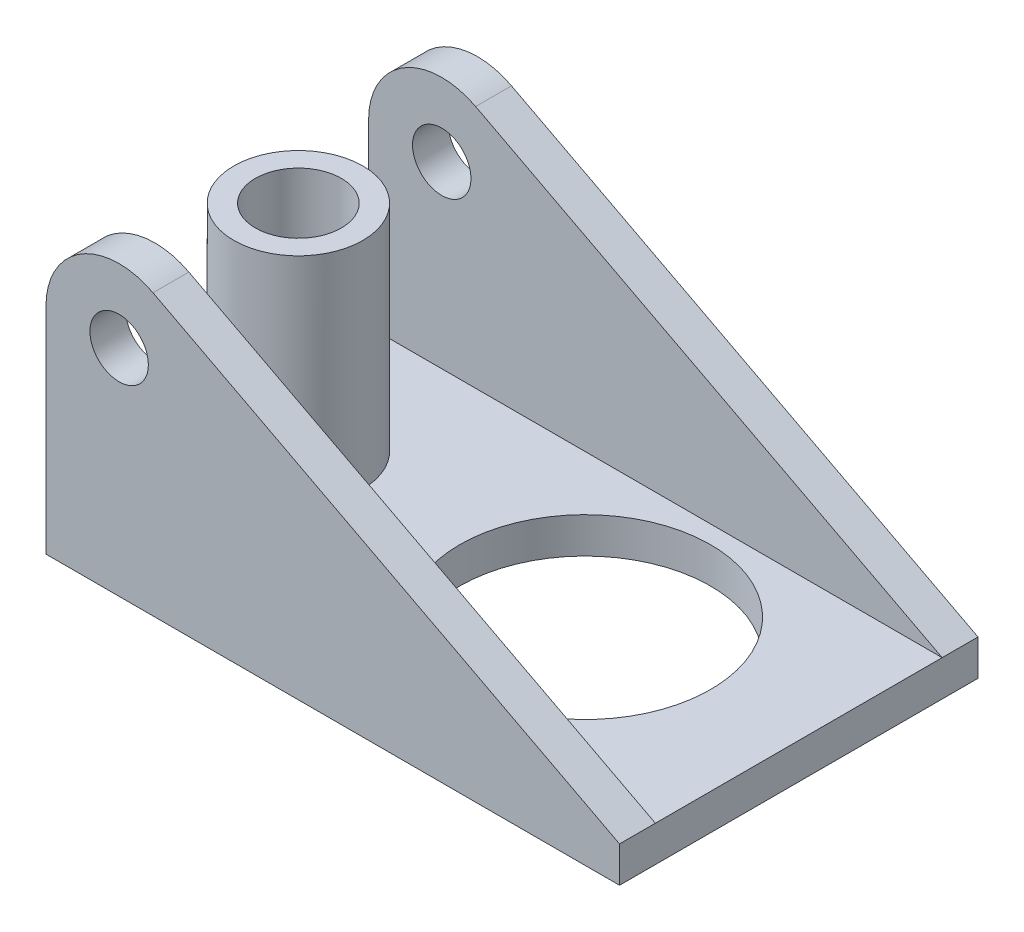
from build123d import *

# Parameters (mm, degrees)
SKETCH3_R           = 4.075
BOSS_EXTRUDE3_DEPTH = 50
CUT_EXTRUDE1_DEPTH  = 40
SKETCH8_R           = 6
SKETCH8_R_2         = 17.5
CUT_EXTRUDE2_DEPTH  = 6
SKETCH9_R           = 9
SKETCH9_R_2         = 6
BOSS_EXTRUDE4_DEPTH = 30


with BuildPart() as part:
    # Sketch3 → Boss-Extrude3 (new body)
    with BuildSketch(Plane.XY):
        with BuildLine():
            Line((0, 0), (0, 25))
            ThreePointArc((0, 25), (4.917135927, 33.725327913), (14.927715135, 34.038180658))
            Line((14.927715135, 34.038180658), (80, 0))
            Line((80, 0), (80, -5))
            Line((80, -5), (0, -5))
            Line((0, -5), (0, 0))
        make_face()
        with Locations((10.2, 25)):
            Circle(SKETCH3_R, mode=Mode.SUBTRACT)
    extrude(amount=BOSS_EXTRUDE3_DEPTH)

    # Sketch6 → Cut-Extrude1 (cut)
    with BuildSketch(Plane.XY.offset(45)):
        with BuildLine():
            Line((0, 25), (0, 0))
            Line((0, 0), (80, 0))
            Line((80, 0), (14.927715135, 34.038180658))
            ThreePointArc((14.927715135, 34.038180658), (4.917135927, 33.725327913), (0, 25))
        make_face()
    extrude(amount=-CUT_EXTRUDE1_DEPTH, mode=Mode.SUBTRACT)

    # Sketch8 → Cut-Extrude2 (cut, through all)
    with BuildSketch(Plane(origin=(0, 0, 0), x_dir=(1, 0, 0), z_dir=(0, 1, 0))):
        with Locations((10.2, -25)):
            Circle(SKETCH8_R)
        with Locations((50.2, -25)):
            Circle(SKETCH8_R_2)
    extrude(amount=-CUT_EXTRUDE2_DEPTH, mode=Mode.SUBTRACT)

    # Sketch9 → Boss-Extrude4 (add)
    with BuildSketch(Plane(origin=(0, 0, 0), x_dir=(1, 0, 0), z_dir=(0, 1, 0))):
        with Locations((10.2, -25)):
            Circle(SKETCH9_R)
        with Locations((10.2, -25)):
            Circle(SKETCH9_R_2, mode=Mode.SUBTRACT)
    extrude(amount=BOSS_EXTRUDE4_DEPTH)


solid = part.part
